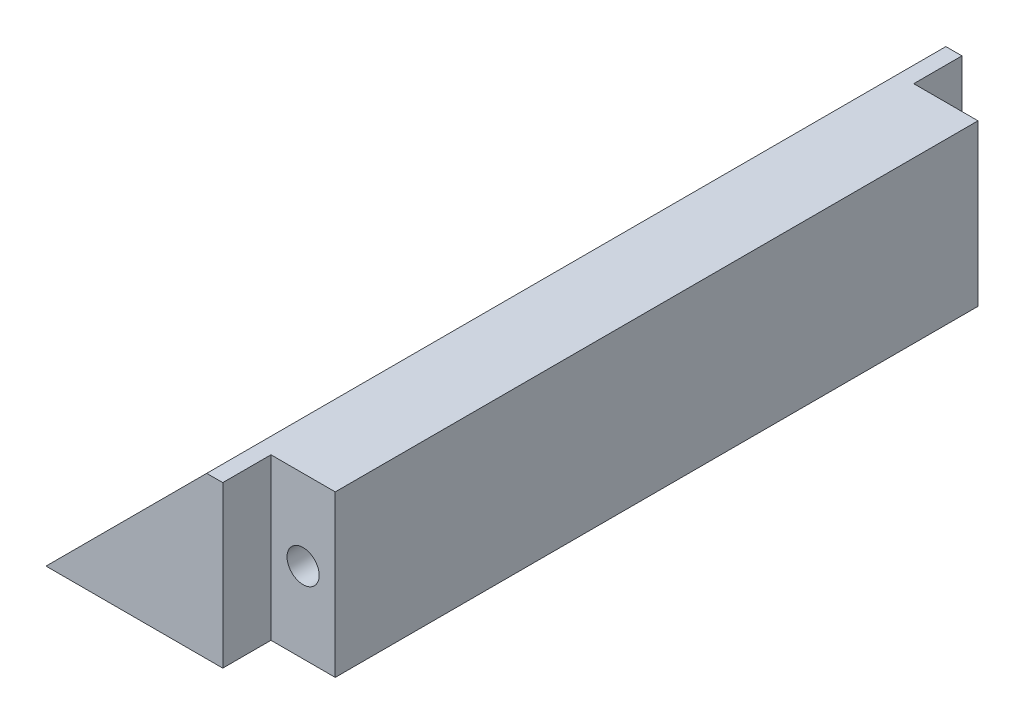
from build123d import *

# Parameters (mm, degrees)
BOSS_EXTRUDE1_DEPTH = 52
SKETCH4_W           = 4
SKETCH4_H           = 10
CUT_EXTRUDE1_DEPTH  = 6
SKETCH5_W           = 4
SKETCH5_H           = 10
CUT_EXTRUDE2_DEPTH  = 6
CUT_EXTRUDE3_DEPTH  = 3
CUT_EXTRUDE4_DEPTH  = 3
SKETCH8_R           = 1
CUT_EXTRUDE5_DEPTH  = 10
SKETCH9_R           = 1
CUT_EXTRUDE6_DEPTH  = 10


with BuildPart() as part:
    # Sketch1 → Boss-Extrude1 (new body)
    with BuildSketch(Plane.XY):
        Polygon((-37.100108605, 13.346711561), (-47.100108605, 3.346711561), (-32.100108605, 3.346711561), (-32.100108605, 13.346711561), align=None)
    extrude(amount=BOSS_EXTRUDE1_DEPTH)

    # Sketch4 → Cut-Extrude1 (cut)
    with BuildSketch(Plane.XY.offset(52)):
        with Locations((-34.100108605, 8.346711561)):
            Rectangle(SKETCH4_W, SKETCH4_H)
    extrude(amount=-CUT_EXTRUDE1_DEPTH, mode=Mode.SUBTRACT)

    # Sketch5 → Cut-Extrude2 (cut)
    with BuildSketch(Plane(origin=(0, 0, 0), x_dir=(-1, 0, 0), z_dir=(0, 0, -1))):
        with Locations((34.100108605, 8.346711561)):
            Rectangle(SKETCH5_W, SKETCH5_H)
    extrude(amount=-CUT_EXTRUDE2_DEPTH, mode=Mode.SUBTRACT)

    # Sketch6 → Cut-Extrude3 (cut)
    with BuildSketch(Plane.XY.offset(52)):
        Polygon((-47.100108605, 3.346711561), (-37.100108605, 13.346711561), (-36.100108605, 13.346711561), (-36.100108605, 3.346711561), align=None)
    extrude(amount=-CUT_EXTRUDE3_DEPTH, mode=Mode.SUBTRACT)

    # Sketch7 → Cut-Extrude4 (cut)
    with BuildSketch(Plane(origin=(0, 0, 0), x_dir=(-1, 0, 0), z_dir=(0, 0, -1))):
        Polygon((47.100108605, 3.346711561), (37.100108605, 13.346711561), (36.100108605, 13.346711561), (36.100108605, 3.346711561), align=None)
    extrude(amount=-CUT_EXTRUDE4_DEPTH, mode=Mode.SUBTRACT)

    # Sketch8 → Cut-Extrude5 (cut)
    with BuildSketch(Plane(origin=(0, 0, 6), x_dir=(-1, 0, 0), z_dir=(0, 0, -1))):
        with Locations((34.100108605, 8.346711561)):
            Circle(SKETCH8_R)
    extrude(amount=-CUT_EXTRUDE5_DEPTH, mode=Mode.SUBTRACT)

    # Sketch9 → Cut-Extrude6 (cut)
    with BuildSketch(Plane.XY.offset(46)):
        with Locations((-34.100108605, 8.346711561)):
            Circle(SKETCH9_R)
    extrude(amount=-CUT_EXTRUDE6_DEPTH, mode=Mode.SUBTRACT)


solid = part.part
